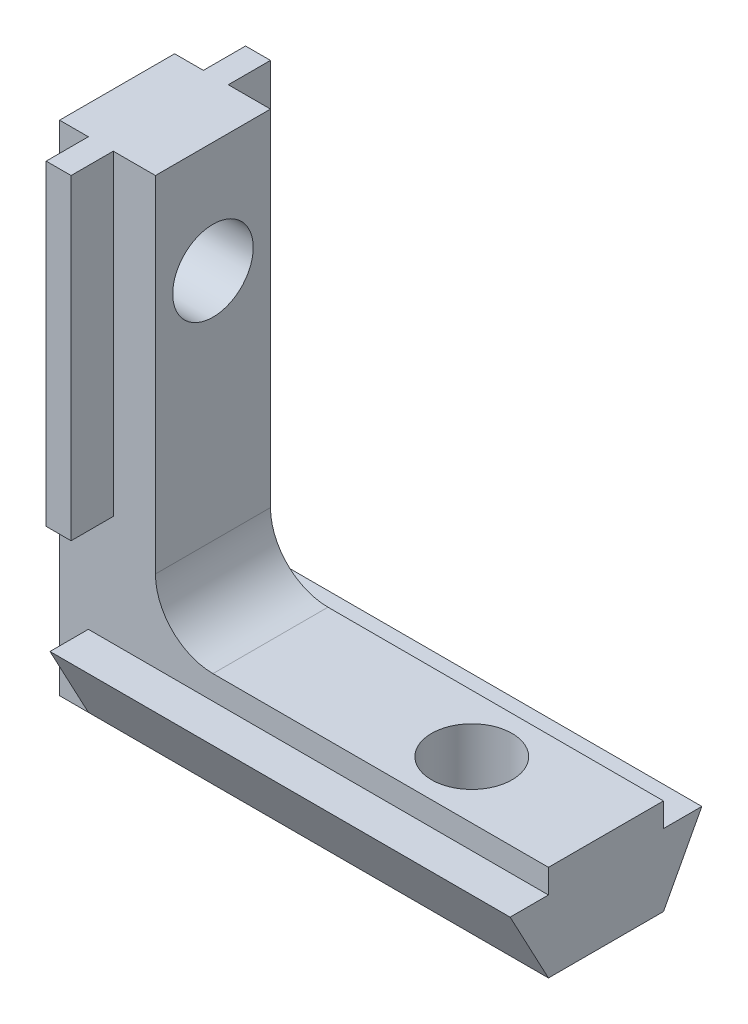
from build123d import *

# Parameters (mm, degrees)
BOSS_EXTRUDE1_DEPTH   = 3
BOSS_EXTRUDE2_DEPTH   = 24
SKETCH3_W             = 1.3
SKETCH3_H             = 10.4
BOSS_EXTRUDE3_DEPTH   = 16.5
M5X0_8_TAPPED_HOLE1_D = 4.2
M5X0_8_TAPPED_HOLE2_D = 4.2


with BuildPart() as part:
    # Sketch1 → Boss-Extrude1 (new body, symmetric)
    with BuildSketch(Plane.XY):
        with BuildLine():
            Line((0, 26), (0, 0))
            Line((0, 0), (25.5, 0))
            Line((25.5, 0), (25.5, 5))
            Line((25.5, 5), (8, 5))
            ThreePointArc((8, 5), (5.878679656, 5.878679656), (5, 8))
            Line((5, 8), (5, 26))
            Line((5, 26), (0, 26))
        make_face()
    extrude(amount=BOSS_EXTRUDE1_DEPTH, both=True)

    # Sketch2 → Boss-Extrude2 (add)
    with BuildSketch(Plane(origin=(25.5, 0, 0), x_dir=(0, 0, -1), z_dir=(1, 0, 0))):
        Polygon((-3, 0), (-5, 3.75), (5, 3.75), (3, 0), align=None)
    extrude(amount=-BOSS_EXTRUDE2_DEPTH)

    # Sketch3 → Boss-Extrude3 (add)
    with BuildSketch(Plane(origin=(0, 26, 0), x_dir=(1, 0, 0), z_dir=(0, 1, 0))):
        with Locations((2.15, 0)):
            Rectangle(SKETCH3_W, SKETCH3_H)
    extrude(amount=-BOSS_EXTRUDE3_DEPTH)

    # M5x0.8 Tapped Hole1 (through all)
    with Locations(Plane(origin=(0, 5, 0), x_dir=(1, 0, 0), z_dir=(0, 1, 0))):
        with Locations((18.5, 0)):
            Hole(M5X0_8_TAPPED_HOLE1_D / 2)

    # M5x0.8 Tapped Hole2 (through all)
    with Locations(Plane(origin=(5, 0, 0), x_dir=(0, 0, -1), z_dir=(1, 0, 0))):
        with Locations((0, 20.2)):
            Hole(M5X0_8_TAPPED_HOLE2_D / 2)


solid = part.part
